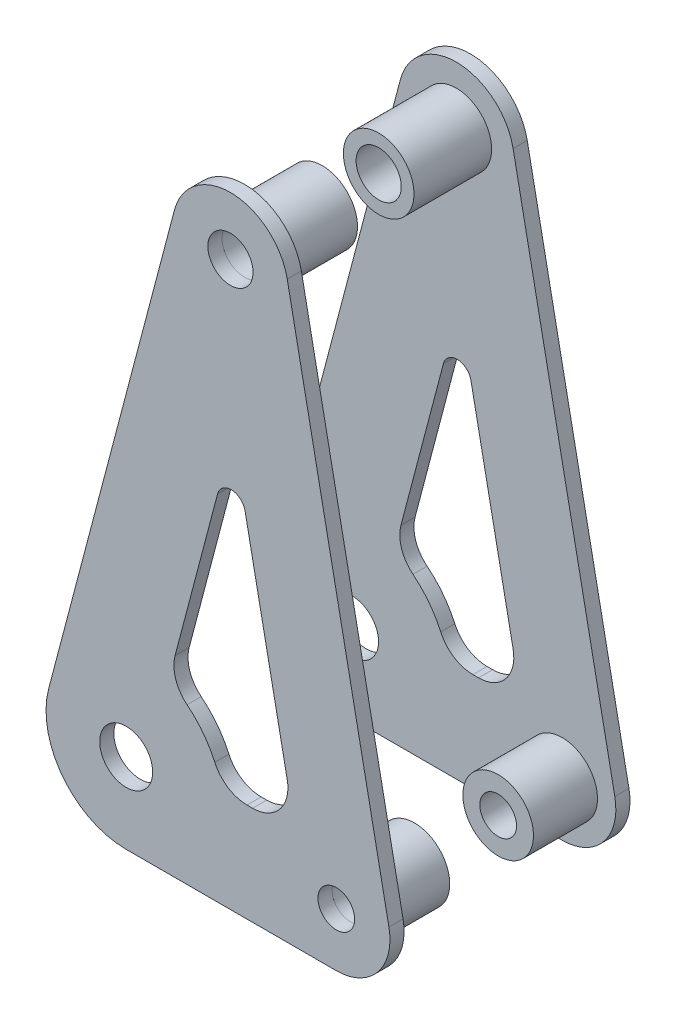
from build123d import *

# Parameters (mm, degrees)
BELLCRANK_START       = 19.05
SKETCH4_R             = 4.064
SKETCH4_R_2           = 3.302
SKETCH4_R_3           = 4.7625
BELLCRANK_PLATE_DEPTH = 2.54
SKETCH5_R             = 6.35
SKETCH5_R_2           = 3.302
PULL_ROD_WASHER_DEPTH = 11.5189
SKETCH6_R             = 6.35
SKETCH6_R_2           = 4.064
DAMPER_WASHER_DEPTH   = 13.97


with BuildPart() as part:
    # Sketch4 → Bellcrank Plate (new body)
    with BuildSketch(Plane.XY.offset(BELLCRANK_START)):
        with BuildLine():
            Line((-13.938846994, 3.672377258), (8.687231987, 89.551749343))
            ThreePointArc((8.687231987, 89.551749343), (19.074657941, 97.307750165), (28.970759131, 88.933901114))
            Line((28.970759131, 88.933901114), (47.267037407, -2.876103068))
            ThreePointArc((47.267037407, -2.876103068), (45.263363465, -10.884329825), (37.801171857, -14.4145))
            Line((37.801171857, -14.4145), (0, -14.4145))
            ThreePointArc((0, -14.4145), (-11.417383506, -8.798929715), (-13.938846994, 3.672377258))
        make_face()
        with Locations((18.757588406, 86.898578108)):
            Circle(SKETCH4_R, mode=Mode.SUBTRACT)
        with Locations((37.801171857, -4.7625)):
            Circle(SKETCH4_R_2, mode=Mode.SUBTRACT)
        Circle(SKETCH4_R_3, mode=Mode.SUBTRACT)
        with BuildLine():
            Line((16.436771041, 49.177310547), (8.793234212, 20.1655607))
            ThreePointArc((8.793234212, 20.1655607), (8.901387915, 16.564401008), (10.951376658, 13.601700465))
            ThreePointArc((10.951376658, 13.601700465), (13.831632, 10.659496351), (15.94294691, 7.1247))
            ThreePointArc((15.94294691, 7.1247), (18.28560864, 4.387551051), (21.740382149, 3.3655))
            Line((21.740382149, 3.3655), (22.743190098, 3.3655))
            ThreePointArc((22.743190098, 3.3655), (27.652526682, 5.687980378), (28.970733223, 10.956550613))
            Line((28.970733223, 10.956550613), (21.383972784, 49.026615857))
            ThreePointArc((21.383972784, 49.026615857), (18.970289567, 51.069018064), (16.436771041, 49.177310547))
        make_face(mode=Mode.SUBTRACT)
    extrude(amount=BELLCRANK_PLATE_DEPTH)


with BuildPart() as body_2:
    # Sketch5 → Pull Rod Washer (new body)
    with BuildSketch(Plane(origin=(0, 0, 19.05), x_dir=(-1, 0, 0), z_dir=(0, 0, -1))):
        with Locations((-37.801171857, -4.7625)):
            Circle(SKETCH5_R)
        with Locations((-37.801171857, -4.7625)):
            Circle(SKETCH5_R_2, mode=Mode.SUBTRACT)
    extrude(amount=PULL_ROD_WASHER_DEPTH)


with BuildPart() as body_3:
    # Sketch6 → Damper Washer (new body)
    with BuildSketch(Plane(origin=(0, 0, 19.05), x_dir=(-1, 0, 0), z_dir=(0, 0, -1))):
        with Locations((-18.757588406, 86.898578108)):
            Circle(SKETCH6_R)
        with Locations((-18.757588406, 86.898578108)):
            Circle(SKETCH6_R_2, mode=Mode.SUBTRACT)
    extrude(amount=DAMPER_WASHER_DEPTH)


with BuildPart() as body_4:
    # Bellcrank Mirror: mirrored copy
    add(part.part.mirror(Plane.XY))


with BuildPart() as body_5:
    # Bellcrank Mirror 2: mirrored copy
    add(body_2.part.mirror(Plane.XY))


with BuildPart() as body_6:
    # Bellcrank Mirror 3: mirrored copy
    add(body_3.part.mirror(Plane.XY))


solid = Compound([part.part, body_2.part, body_3.part, body_4.part, body_5.part, body_6.part])
